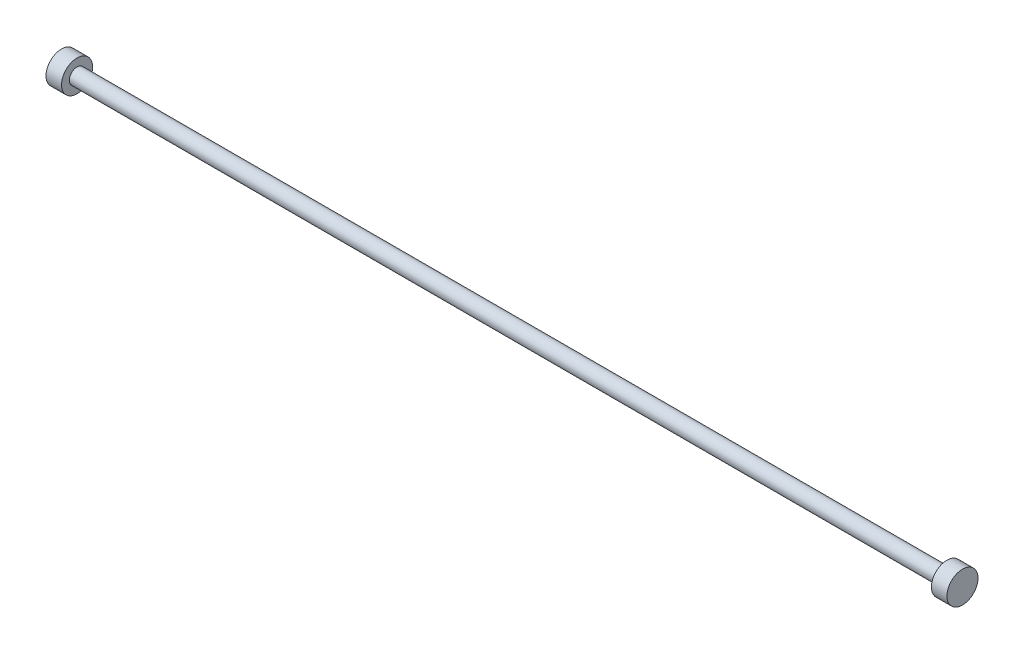
from build123d import *

# Parameters (mm, degrees)
SKETCH1_R           = 5
BOSS_EXTRUDE1_DEPTH = 560
SKETCH2_R           = 10
BOSS_EXTRUDE2_DEPTH = 10
SKETCH3_R           = 10
BOSS_EXTRUDE3_DEPTH = 10


with BuildPart() as part:
    # Sketch1 → Boss-Extrude1 (new body)
    with BuildSketch(Plane(origin=(0, 0, 0), x_dir=(0, 0, -1), z_dir=(1, 0, 0))):
        Circle(SKETCH1_R)
    extrude(amount=BOSS_EXTRUDE1_DEPTH)

    # Sketch2 → Boss-Extrude2 (add)
    with BuildSketch(Plane(origin=(560, 0, 0), x_dir=(0, 0, -1), z_dir=(1, 0, 0))):
        Circle(SKETCH2_R)
    extrude(amount=BOSS_EXTRUDE2_DEPTH)

    # Sketch3 → Boss-Extrude3 (add)
    with BuildSketch(Plane.ZY):
        Circle(SKETCH3_R)
    extrude(amount=BOSS_EXTRUDE3_DEPTH)


solid = part.part
